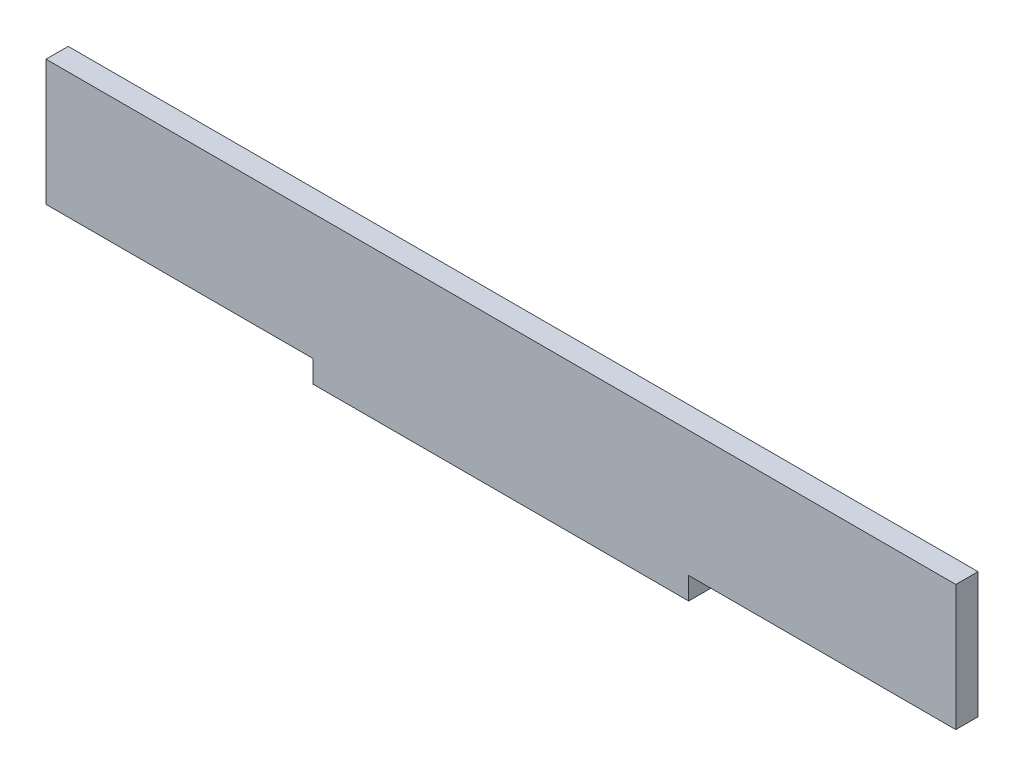
from build123d import *

# Parameters (mm, degrees)
BOSS_EXTRUDE1_DEPTH = 3


with BuildPart() as part:
    # Sketch1 → Boss-Extrude1 (new body)
    with BuildSketch(Plane.XY):
        Polygon((25.386829775, -8.5), (61.5, -8.5), (61.5, 8.5), (-61.5, 8.5), (-61.5, -8.5), (-25.386829775, -8.5), (-25.386829775, -11.5), (25.386829775, -11.5), align=None)
    extrude(amount=BOSS_EXTRUDE1_DEPTH)


solid = part.part
